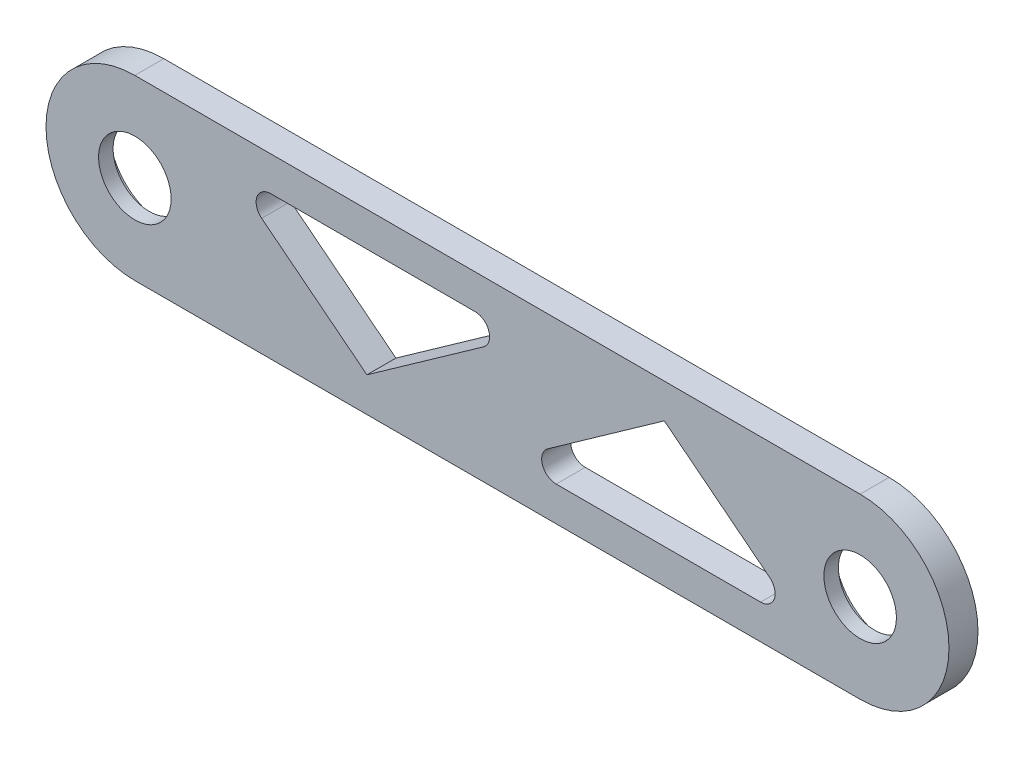
from build123d import *

# Parameters (mm, degrees)
SKETCH_1_R          = 5
EXTRUDE_1_DEPTH     = 4
SKETCH_4_R          = 7.5
CUT_EXTRUDE_3_DEPTH = 3
CUT_EXTRUDE_4_REACH = 6


with BuildPart() as part:
    # 草图1 → 凸台-拉伸1 (new body)
    with BuildSketch(Plane.XY):
        with BuildLine():
            Line((0, 12.25), (100, 12.25))
            ThreePointArc((100, 12.25), (112.25, 0), (100, -12.25))
            Line((100, -12.25), (0, -12.25))
            ThreePointArc((0, -12.25), (-12.25, 0), (0, 12.25))
        make_face()
        Circle(SKETCH_1_R, mode=Mode.SUBTRACT)
        with Locations((100, 0)):
            Circle(SKETCH_1_R, mode=Mode.SUBTRACT)
    extrude(amount=EXTRUDE_1_DEPTH)

    # 草图4 → 切除-拉伸3 (cut)
    with BuildSketch(Plane.XY.offset(2)):
        Circle(SKETCH_4_R)
        with Locations((100, 0)):
            Circle(SKETCH_4_R)
    extrude(amount=-CUT_EXTRUDE_3_DEPTH, mode=Mode.SUBTRACT)

    # 草图5 → 切除-拉伸4 (cut, up to next)
    with BuildSketch(Plane(origin=(0, 0, 0), x_dir=(-1, 0, 0), z_dir=(0, 0, -1)), mode=Mode.PRIVATE) as cut_extrude_4_sk1:
        with BuildLine():
            Line((-73, 7.5), (-87.516221291, -3.928572043))
            ThreePointArc((-87.516221291, -3.928572043), (-88.168863565, -6.15465414), (-86.279041363, -7.5))
            Line((-86.279041363, -7.5), (-58.092346966, -7.5))
            ThreePointArc((-58.092346966, -7.5), (-56.186421499, -6.106174988), (-56.937022619, -3.867448116))
            Line((-56.937022619, -3.867448116), (-73, 7.5))
        make_face()
    cut_extrude_4_tool1 = extrude(cut_extrude_4_sk1.sketch, amount=-CUT_EXTRUDE_4_REACH, mode=Mode.PRIVATE) & part.part
    add(cut_extrude_4_tool1.solids().sort_by_distance((72.350084, -2.302404, 0))[0], mode=Mode.SUBTRACT)
    # 草图5 → 切除-拉伸4 (cut, up to next)
    with BuildSketch(Plane(origin=(0, 0, 0), x_dir=(-1, 0, 0), z_dir=(0, 0, -1)), mode=Mode.PRIVATE) as cut_extrude_4_sk2:
        with BuildLine():
            Line((-32, -7.5), (-17.483778709, 3.928572043))
            ThreePointArc((-17.483778709, 3.928572043), (-16.831136435, 6.15465414), (-18.720958637, 7.5))
            Line((-18.720958637, 7.5), (-46.907653034, 7.5))
            ThreePointArc((-46.907653034, 7.5), (-48.813578501, 6.106174988), (-48.062977381, 3.867448116))
            Line((-48.062977381, 3.867448116), (-32, -7.5))
        make_face()
    cut_extrude_4_tool2 = extrude(cut_extrude_4_sk2.sketch, amount=-CUT_EXTRUDE_4_REACH, mode=Mode.PRIVATE) & part.part
    add(cut_extrude_4_tool2.solids().sort_by_distance((32.649916, 2.302404, 0))[0], mode=Mode.SUBTRACT)


solid = part.part
